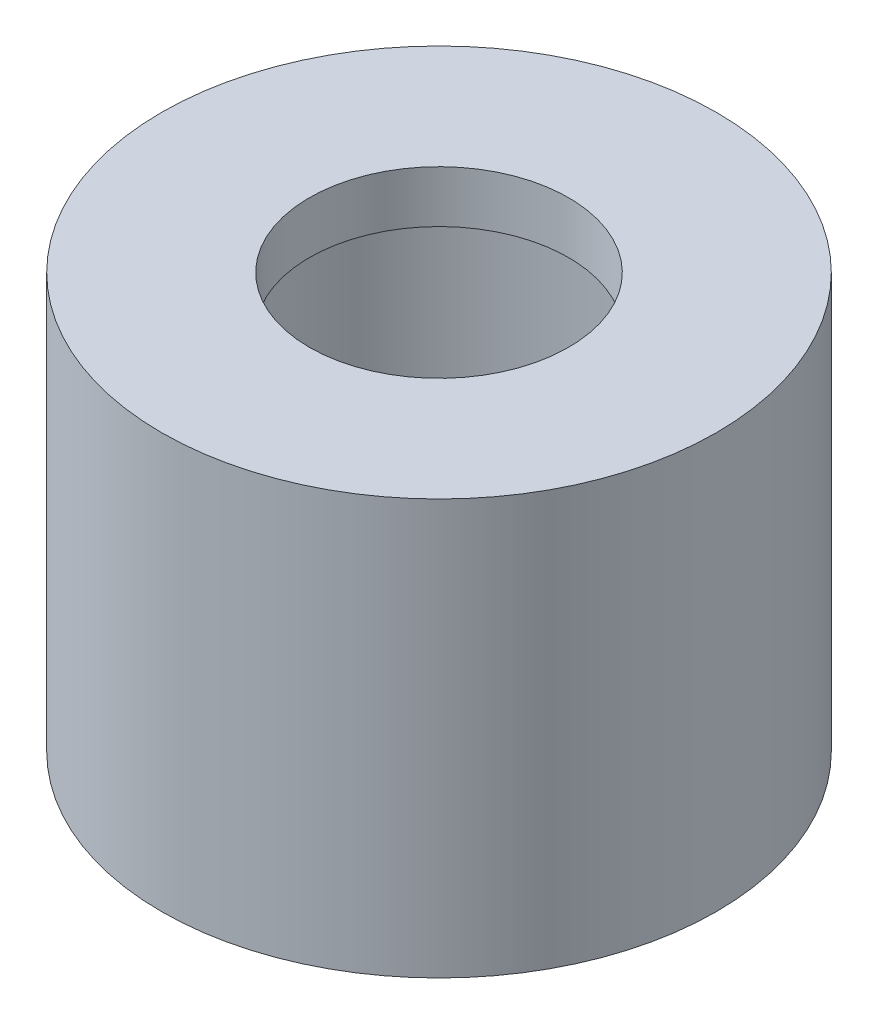
from build123d import *

# Parameters (mm, degrees)
SKETCH_1_R          = 5.35
SKETCH_1_R_2        = 4
EXTRUDE_1_DEPTH     = 3
SKETCH_2_R          = 5.35
SKETCH_2_R_2        = 4
EXTRUDE_2_DEPTH     = 5
SKETCH_3_R          = 4
EXTRUDE_3_DEPTH     = 1
SKETCH_4_R          = 2.5
CUT_EXTRUDE_1_DEPTH = 1


with BuildPart() as part:
    # 草图1 → 凸台-拉伸1 (new body)
    with BuildSketch(Plane(origin=(0, 0, 0), x_dir=(1, 0, 0), z_dir=(0, 1, 0))):
        Circle(SKETCH_1_R)
        Circle(SKETCH_1_R_2, mode=Mode.SUBTRACT)
    extrude(amount=EXTRUDE_1_DEPTH)

    # 草图2 → 凸台-拉伸2 (add)
    with BuildSketch(Plane.XZ):
        Circle(SKETCH_2_R)
        Circle(SKETCH_2_R_2, mode=Mode.SUBTRACT)
    extrude(amount=EXTRUDE_2_DEPTH)

    # 草图3 → 凸台-拉伸3 (add)
    with BuildSketch(Plane(origin=(0, 3, 0), x_dir=(1, 0, 0), z_dir=(0, 1, 0))):
        Circle(SKETCH_3_R)
    extrude(amount=-EXTRUDE_3_DEPTH)

    # 草图4 → 切除-拉伸1 (cut)
    with BuildSketch(Plane(origin=(0, 3, 0), x_dir=(1, 0, 0), z_dir=(0, 1, 0))):
        Circle(SKETCH_4_R)
    extrude(amount=-CUT_EXTRUDE_1_DEPTH, mode=Mode.SUBTRACT)


solid = part.part
